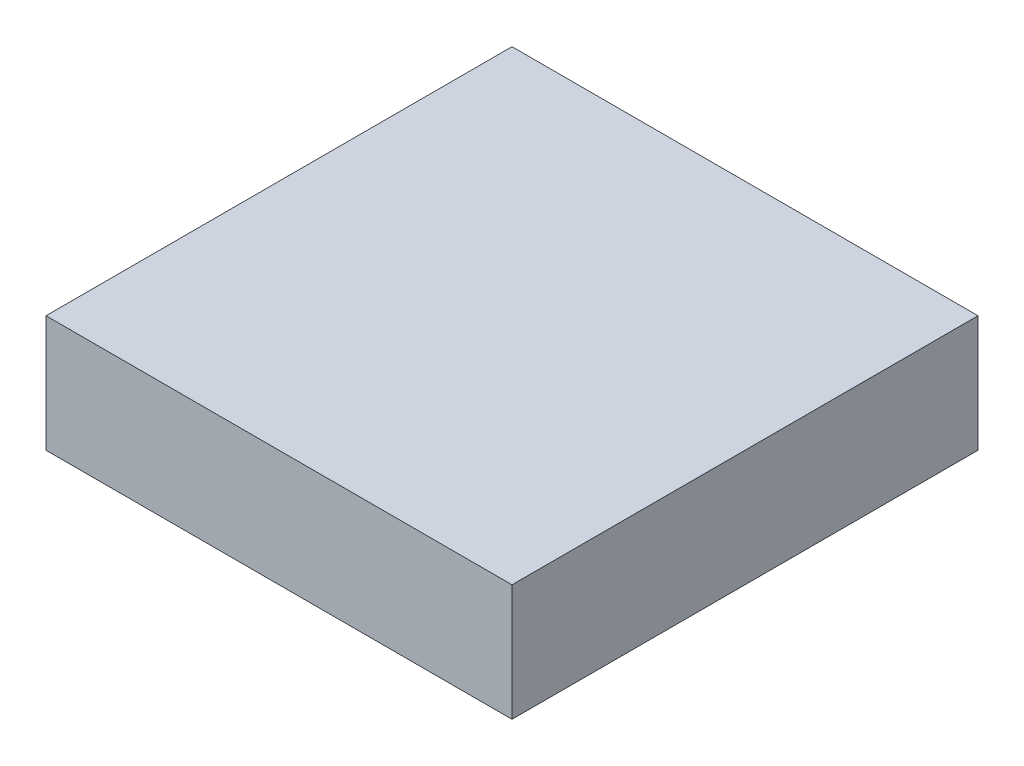
from build123d import *

# Parameters (mm, degrees)
SKETCH1_W           = 12192
SKETCH1_H           = 12192
BOSS_EXTRUDE1_DEPTH = 3048


with BuildPart() as part:
    # Sketch1 → Boss-Extrude1 (new body)
    with BuildSketch(Plane(origin=(0, 0, 0), x_dir=(1, 0, 0), z_dir=(0, 1, 0))):
        Rectangle(SKETCH1_W, SKETCH1_H)
    extrude(amount=-BOSS_EXTRUDE1_DEPTH)


solid = part.part
